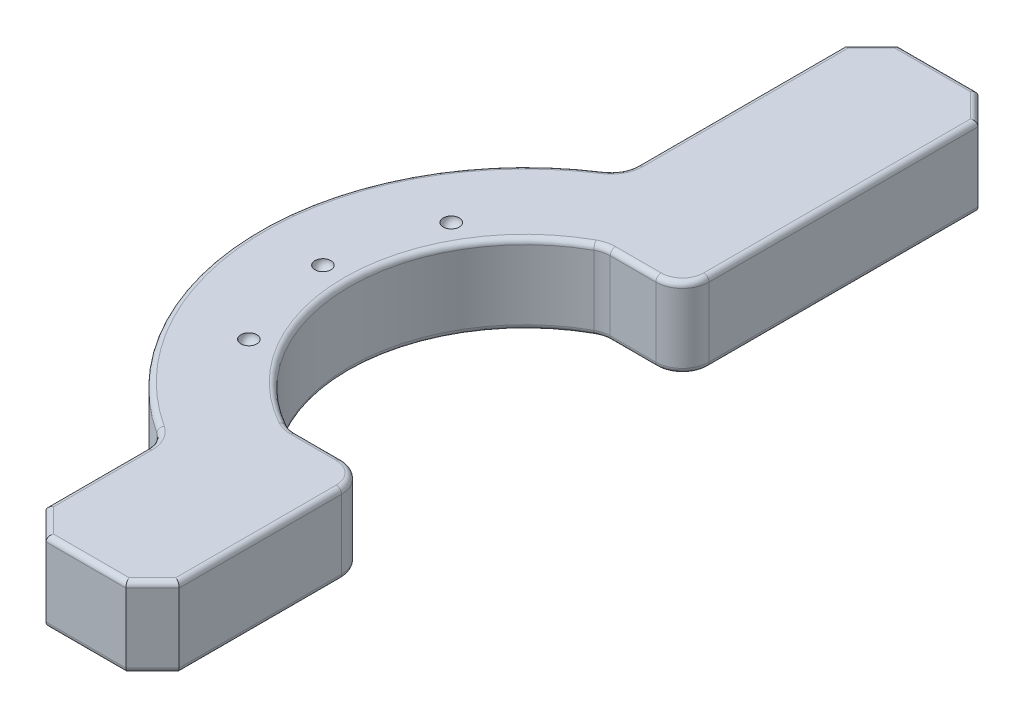
from build123d import *

# Parameters (mm, degrees)
BOSS_EXTRUDE2_DEPTH = 7.5
SKETCH2_W           = 40.5
SKETCH2_H           = 15
SKETCH2_W_2         = 60.5
BOSS_EXTRUDE3_DEPTH = 25
CIRPATTERN1_COUNT   = 2
CIRPATTERN1_ANGLE   = 30
CIRPATTERN2_COUNT   = 2
CIRPATTERN2_ANGLE   = 30
FILLET1_R           = 5
CHAMFER1_SIZE       = 5
FILLET2_R           = 1


with BuildPart() as part:
    # Sketch1 → Boss-Extrude2 (new body, symmetric)
    with BuildSketch(Plane(origin=(0, 0, 0), x_dir=(1, 0, 0), z_dir=(0, 1, 0))):
        with BuildLine():
            Line((50, 130), (50, 113))
            ThreePointArc((50, 113), (17, 80), (50, 47))
            Line((50, 47), (50, 30))
            ThreePointArc((50, 30), (0, 80), (50, 130))
        make_face()
    extrude(amount=BOSS_EXTRUDE2_DEPTH, both=True)

    # Sketch2 → Boss-Extrude3 (add)
    with BuildSketch(Plane(origin=(50, 0, 0), x_dir=(0, 0, -1), z_dir=(1, 0, 0))):
        with Locations((30.25, 0)):
            Rectangle(SKETCH2_W, SKETCH2_H)
        with Locations((139.75, 0)):
            Rectangle(SKETCH2_W_2, SKETCH2_H)
    extrude(amount=-BOSS_EXTRUDE3_DEPTH)

    # Sketch3 → Cut-Revolve3 (revolve, cut)
    with BuildSketch(Plane(origin=(0, 7.5, 0), x_dir=(1, 0, 0), z_dir=(0, 1, 0))):
        with BuildLine():
            Line((12, 81.5), (12, 78.5))
            ThreePointArc((12, 78.5), (10.5, 80), (12, 81.5))
        make_face()
    cut_revolve3 = revolve(axis=Axis((12, 7.5, -81.5), (0, 0, 1)), mode=Mode.SUBTRACT)

    # CirPattern1: Cut-Revolve3 ×2 about axis
    cirpattern1_axis = Axis((50, 0, -80), (0, 1, 0))
    for i in range(1, CIRPATTERN1_COUNT):
        add(cut_revolve3.rotate(cirpattern1_axis, i * CIRPATTERN1_ANGLE / (CIRPATTERN1_COUNT - 1)), mode=Mode.SUBTRACT)

    # CirPattern2: Cut-Revolve3 ×2 about axis
    cirpattern2_axis = Axis((50, 0, -80), (0, -1, 0))
    for i in range(1, CIRPATTERN2_COUNT):
        add(cut_revolve3.rotate(cirpattern2_axis, i * CIRPATTERN2_ANGLE / (CIRPATTERN2_COUNT - 1)), mode=Mode.SUBTRACT)

    # Mirror1: Cut-Revolve3 across plane
    add(cut_revolve3.mirror(Plane.ZX), mode=Mode.SUBTRACT)

    # Mirror1 copy 1 sketch → Mirror1 copy 1 (revolve, cut)
    with BuildSketch(Plane(origin=(-33.301270189, -7.5, -35.717967697), x_dir=(0.866025404, 0, 0.5), z_dir=(0, -1, 0))):
        with BuildLine():
            Line((12, -81.5), (12, -78.5))
            ThreePointArc((12, -78.5), (10.5, -80), (12, -81.5))
        make_face()
    revolve(axis=Axis((17.841034656, -7.5, -100.299038106), (0.5, 0, -0.866025404)), mode=Mode.SUBTRACT)

    # Mirror1 copy 2 sketch → Mirror1 copy 2 (revolve, cut)
    with BuildSketch(Plane(origin=(46.698729811, -7.5, 14.282032303), x_dir=(0.866025404, 0, -0.5), z_dir=(0, -1, 0))):
        with BuildLine():
            Line((12, -81.5), (12, -78.5))
            ThreePointArc((12, -78.5), (10.5, -80), (12, -81.5))
        make_face()
    revolve(axis=Axis((16.341034656, -7.5, -62.299038106), (-0.5, 0, -0.866025404)), mode=Mode.SUBTRACT)

    # Fillet1
    fillet1_edges = [part.edges().sort_by_distance(p)[0] for p in [
        (35.209800542, 0, -50.5),
        (25, 0, -36.698729811),
        (50, 0, -50.5),
        (25, 0, -123.301270189),
        (35.209800542, 0, -109.5),
        (50, 0, -109.5),
    ]]
    fillet(fillet1_edges, radius=FILLET1_R)

    # Chamfer1
    chamfer1_edges = [part.edges().sort_by_distance(p)[0] for p in [
        (50, 0, -10),
        (25, 0, -10),
        (50, 0, -170),
        (25, 0, -170),
    ]]
    chamfer(chamfer1_edges, length=CHAMFER1_SIZE)

    # Fillet2
    fillet2_edges = [part.edges().sort_by_distance(p)[0] for p in [
        (35.194558288, -7.5, -109.341229183),
        (35.194558288, 7.5, -109.341229183),
        (35.194558288, 7.5, -50.658770817),
        (35.194558288, -7.5, -50.658770817),
        (24.395245365, 7.5, -36.285934187),
        (24.395245365, -7.5, -36.285934187),
        (24.395245365, 7.5, -123.714065813),
        (24.395245365, -7.5, -123.714065813),
        (37.5, -7.5, -170),
        (37.5, 7.5, -170),
        (50, 7.5, -139.75),
        (25, 7.5, -145.548861143),
        (37.5, 7.5, -10),
        (47.5, 7.5, -12.5),
        (27.5, 7.5, -12.5),
        (47.5, 7.5, -167.5),
        (27.5, 7.5, -167.5),
        (50, -7.5, -139.75),
        (37.5, -7.5, -10),
        (25, -7.5, -24.451138857),
        (47.5, -7.5, -12.5),
        (27.5, -7.5, -12.5),
        (47.5, -7.5, -167.5),
        (27.5, -7.5, -167.5),
        (10.5, -7.5, -80),
        (15.791996551, -7.5, -60.25),
        (18.390072762, -7.5, -98.25),
        (40.722279144, -7.5, -109.5),
        (17, -7.5, -80),
        (40.722279144, -7.5, -50.5),
        (50, -7.5, -30.25),
        (0, -7.5, -80),
        (25, -7.5, -145.548861143),
        (48.535533906, -7.5, -49.035533906),
        (48.535533906, -7.5, -110.964466094),
        (40.722279144, 7.5, -109.5),
        (17, 7.5, -80),
        (0, 7.5, -80),
        (25, 7.5, -24.451138857),
        (50, 7.5, -30.25),
        (40.722279144, 7.5, -50.5),
        (48.535533906, 7.5, -49.035533906),
        (48.535533906, 7.5, -110.964466094),
    ]]
    fillet(fillet2_edges, radius=FILLET2_R)


solid = part.part
